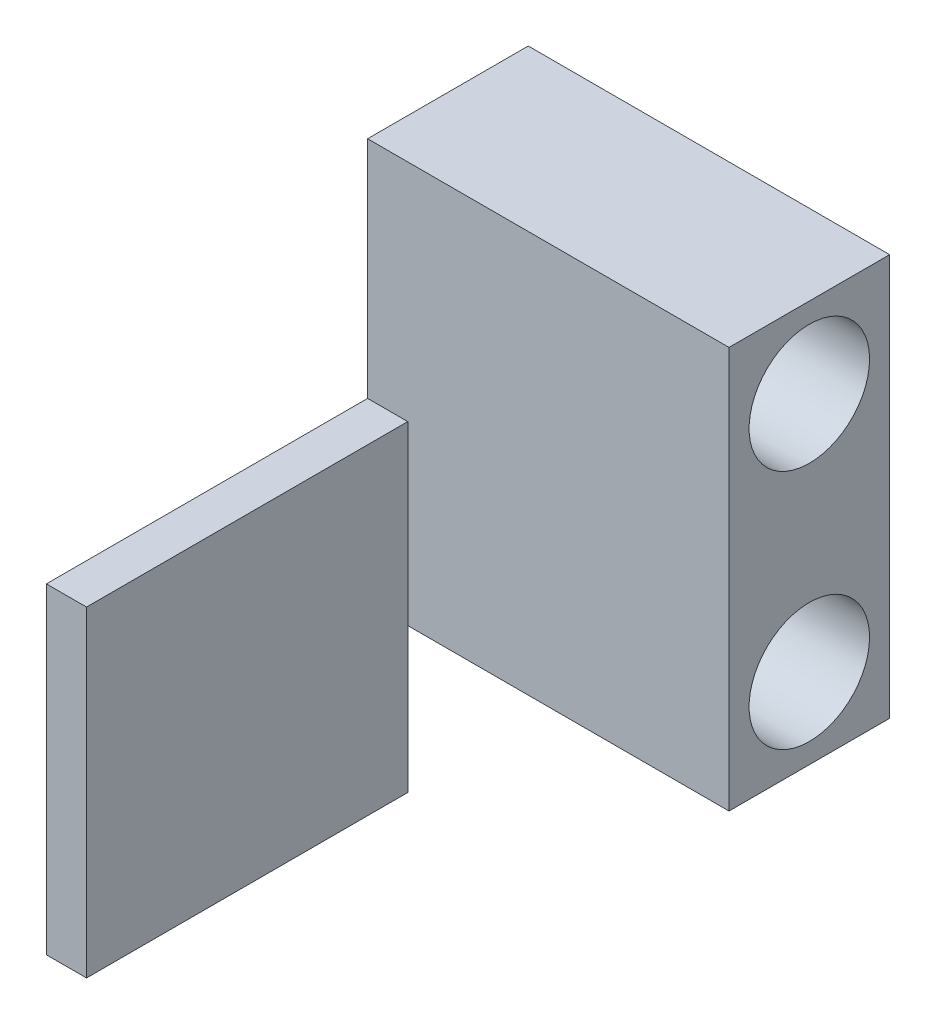
from build123d import *

# Parameters (mm, degrees)
SKETCH2_W               = 20
SKETCH2_H               = 50
BOSS_EXTRUDE1_DEPTH     = 22.5
SKETCH3_W               = 5
SKETCH3_H               = 40
BOSS_EXTRUDE2_DEPTH     = 40
SKETCH4_R               = 7.5
CUT_EXTRUDE1_DEPTH      = 23.5
CUT_EXTRUDE1_DEPTH_BACK = 23.5


with BuildPart() as part:
    # Sketch2 → Boss-Extrude1 (new body, symmetric)
    with BuildSketch(Plane(origin=(0, 0, 0), x_dir=(0, 0, -1), z_dir=(1, 0, 0))):
        Rectangle(SKETCH2_W, SKETCH2_H)
    extrude(amount=BOSS_EXTRUDE1_DEPTH, both=True)

    # Sketch3 → Boss-Extrude2 (add)
    with BuildSketch(Plane.XY.offset(10)):
        with Locations((-20, -23)):
            Rectangle(SKETCH3_W, SKETCH3_H)
    extrude(amount=BOSS_EXTRUDE2_DEPTH)

    # Sketch4 → Cut-Extrude1 (cut, two sides)
    with BuildSketch(Plane(origin=(0, 0, 0), x_dir=(0, 0, -1), z_dir=(1, 0, 0))) as cut_extrude1_sk:
        with Locations((0, -15)):
            Circle(SKETCH4_R)
        with Locations((0, 15)):
            Circle(SKETCH4_R)
    extrude(amount=CUT_EXTRUDE1_DEPTH, mode=Mode.SUBTRACT)
    extrude(cut_extrude1_sk.sketch, amount=-CUT_EXTRUDE1_DEPTH_BACK, mode=Mode.SUBTRACT)


solid = part.part
